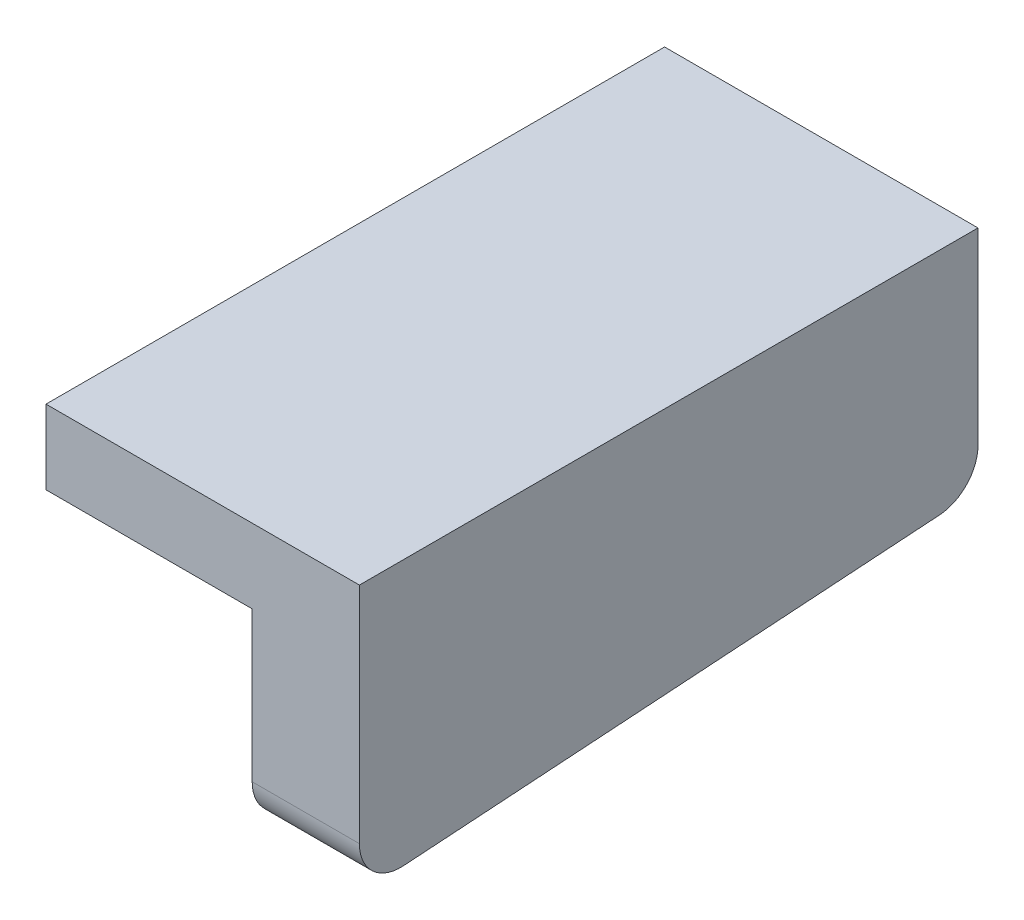
from build123d import *

# Parameters (mm, degrees)
BOSS_EXTRUDE1_DEPTH = 15
CUT_EXTRUDE1_DEPTH  = 15
FILLET1_R           = 1


with BuildPart() as part:
    # Sketch1 → Boss-Extrude1 (new body)
    with BuildSketch(Plane.XY):
        Polygon((-6.3, 15.8), (1.3, 15.8), (1.3, 13.8), (1.3, 8.2), (-1.3, 8.2), (-1.3, 14), (-6.3, 14), align=None)
    extrude(amount=BOSS_EXTRUDE1_DEPTH)

    # Sketch3 → Cut-Extrude1 (cut)
    with BuildSketch(Plane(origin=(1.3, 0, 0), x_dir=(0, 0, -1), z_dir=(1, 0, 0))):
        Polygon((-15, 9.3), (-15.890506456, 6.842306326), (2.099726504, 7.064407967), (0, 10.3), align=None)
    extrude(amount=-CUT_EXTRUDE1_DEPTH, mode=Mode.SUBTRACT)

    # Fillet1
    fillet1_edges = [part.edges().sort_by_distance(p)[0] for p in [
        (0, 10.3, 0),
        (0, 9.3, 15),
    ]]
    fillet(fillet1_edges, radius=FILLET1_R)


solid = part.part
